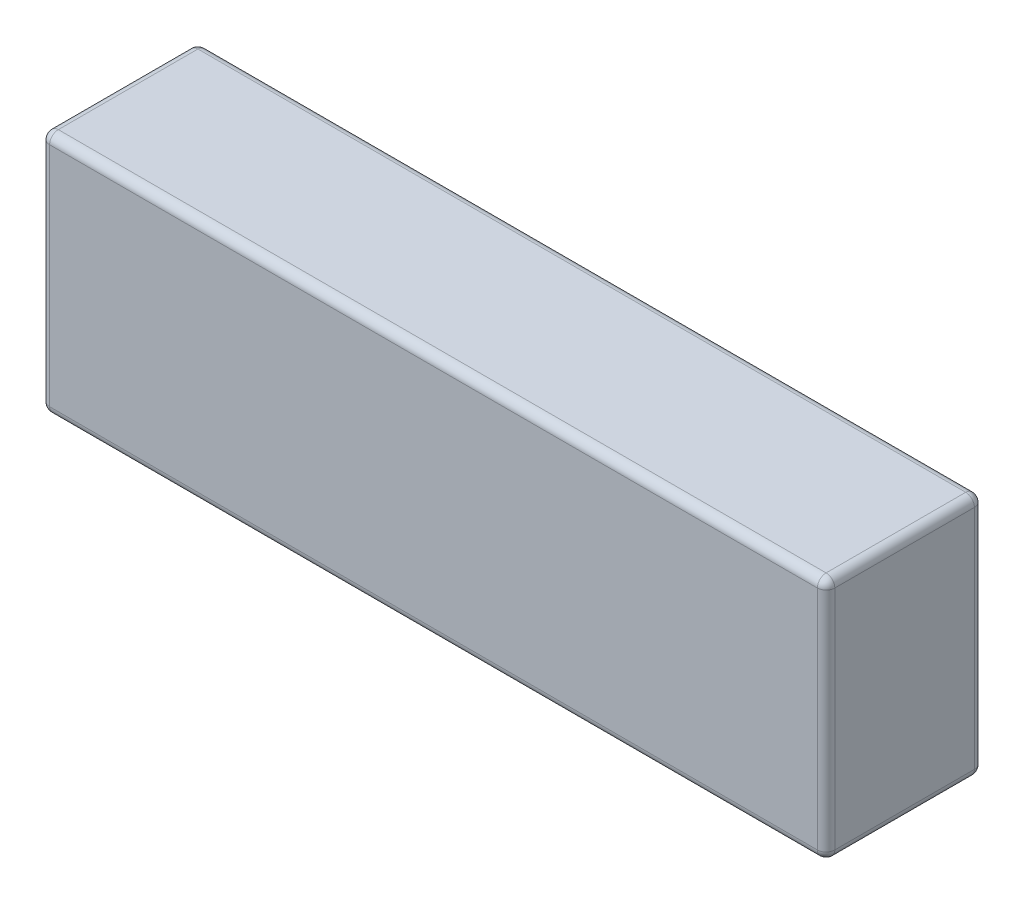
from build123d import *

# Parameters (mm, degrees)
SCHIZZO1_W                   = 90
SCHIZZO1_H                   = 18
ESTRUSIONE_ESTRUSIONE1_DEPTH = 28
RACCORDO1_R                  = 1


with BuildPart() as part:
    # Schizzo1 → Estrusione-Estrusione1 (new body)
    with BuildSketch(Plane(origin=(0, 0, 0), x_dir=(1, 0, 0), z_dir=(0, 1, 0))):
        Rectangle(SCHIZZO1_W, SCHIZZO1_H)
    extrude(amount=ESTRUSIONE_ESTRUSIONE1_DEPTH)

    # Raccordo1
    raccordo1_edges = [part.edges().sort_by_distance(p)[0] for p in [
        (45, 28, 0),
        (0, 28, -9),
        (-45, 28, 0),
        (0, 0, -9),
        (45, 0, 0),
        (0, 0, 9),
        (-45, 0, 0),
        (-45, 14, -9),
        (45, 14, -9),
        (45, 14, 9),
        (-45, 14, 9),
        (0, 28, 9),
    ]]
    fillet(raccordo1_edges, radius=RACCORDO1_R)


solid = part.part
